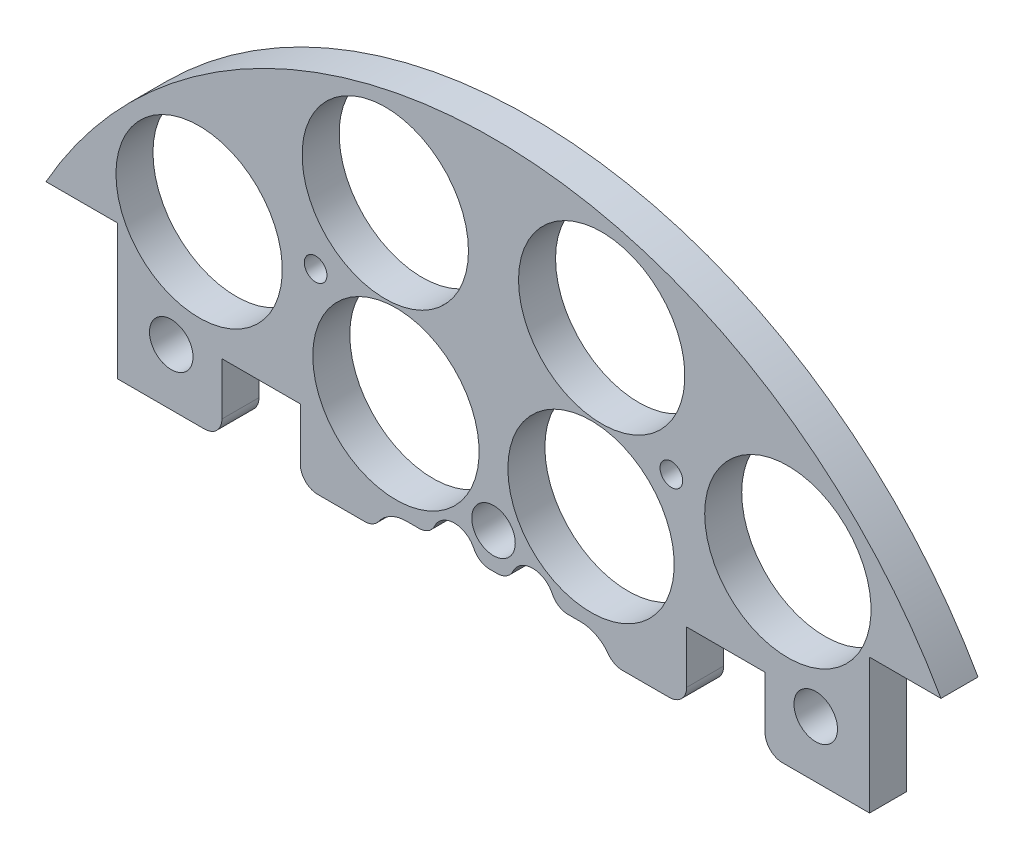
from build123d import *

# Parameters (mm, degrees)
SKETCH1_R                 = 1.651
BOSS_EXTRUDE2_DEPTH       = 5.3975
SKETCH2_R                 = 1.143
CUT_EXTRUDE1_DEPTH        = 6.3975
SKETCH3_R                 = 12.1285
CUT_EXTRUDE2_DEPTH        = 6.3975
SKETCH4_W                 = 28.562713242
SKETCH4_H                 = 11.677503754
BOSS_EXTRUDE3_DEPTH       = 5.3975
SKETCH5_W                 = 230.699333954
SKETCH5_H                 = 107.587024537
CUT_EXTRUDE3_DEPTH        = 6.3975
SKETCH6_R                 = 12.1285
CUT_EXTRUDE4_DEPTH        = 6.3975
SKETCH162_W               = 11.43
SKETCH162_H               = 10.16
CUT_EXTRUDE159_DEPTH      = 6.3975
SKETCH218_R               = 1.651
CUT_EXTRUDE215_DEPTH      = 97.79
SKETCH272_R               = 3.175
CUT_EXTRUDE269_DEPTH      = 103.378
CUT_EXTRUDE269_DEPTH_BACK = 48.768
CUT_EXTRUDE162_DEPTH      = 30.48
FILLET1_R                 = 2.54


with BuildPart() as part:
    # Sketch1 → Boss-Extrude2 (new body)
    with BuildSketch(Plane.XY):
        with BuildLine():
            Line((-65.2537815, 36.83), (-54.8397815, 36.83))
            Line((-54.8397815, 36.83), (-54.8397815, -36.83))
            Line((-54.8397815, -36.83), (-65.2537815, -36.83))
            ThreePointArc((-65.2537815, -36.83), (0, -74.93), (65.2537815, -36.83))
            Line((65.2537815, -36.83), (54.8397815, -36.83))
            Line((54.8397815, -36.83), (54.8397815, 36.83))
            Line((54.8397815, 36.83), (65.2537815, 36.83))
            ThreePointArc((65.2537815, 36.83), (0, 74.93), (-65.2537815, 36.83))
        make_face()
        with Locations((-45.466, 11.049)):
            Circle(SKETCH1_R, mode=Mode.SUBTRACT)
        with Locations((-20.067270032, 10.795)):
            Circle(SKETCH1_R, mode=Mode.SUBTRACT)
        with Locations((-20.067270032, -10.795)):
            Circle(SKETCH1_R, mode=Mode.SUBTRACT)
        with Locations((-45.466, -11.049)):
            Circle(SKETCH1_R, mode=Mode.SUBTRACT)
        with Locations((45.466, -11.049)):
            Circle(SKETCH1_R, mode=Mode.SUBTRACT)
        with Locations((20.067270032, -10.795)):
            Circle(SKETCH1_R, mode=Mode.SUBTRACT)
        with Locations((20.067270032, 10.795)):
            Circle(SKETCH1_R, mode=Mode.SUBTRACT)
        with Locations((45.466, 11.049)):
            Circle(SKETCH1_R, mode=Mode.SUBTRACT)
    extrude(amount=BOSS_EXTRUDE2_DEPTH)

    # Sketch2 → Cut-Extrude1 (cut, through all)
    with BuildSketch(Plane.XY.offset(5.3975)):
        with Locations((-6.731, 62.23)):
            Circle(SKETCH2_R)
        with Locations((6.731, 62.23)):
            Circle(SKETCH2_R)
    extrude(amount=-CUT_EXTRUDE1_DEPTH, mode=Mode.SUBTRACT)

    # Sketch3 → Cut-Extrude2 (cut, through all)
    with BuildSketch(Plane(origin=(0, 0, 0), x_dir=(-1, 0, 0), z_dir=(0, 0, -1))):
        with Locations((-14.224, -56.725087043)):
            Circle(SKETCH3_R)
        with Locations((14.224, -56.725087043)):
            Circle(SKETCH3_R)
        with Locations((-42.926, -42.926)):
            Circle(SKETCH3_R)
        with Locations((14.224, 34.29)):
            Circle(SKETCH3_R)
        with Locations((-14.224, 34.29)):
            Circle(SKETCH3_R)
        with Locations((-42.926, 42.926)):
            Circle(SKETCH3_R)
        with Locations((42.926, 42.926)):
            Circle(SKETCH3_R)
        with Locations((42.926, -42.926)):
            Circle(SKETCH3_R)
    extrude(amount=-CUT_EXTRUDE2_DEPTH, mode=Mode.SUBTRACT)

    # Sketch4 → Boss-Extrude3 (add)
    with BuildSketch(Plane(origin=(0, 0, 0), x_dir=(-1, 0, 0), z_dir=(0, 0, -1))):
        with Locations((-1.488809975, 62.152540216)):
            Rectangle(SKETCH4_W, SKETCH4_H)
    extrude(amount=-BOSS_EXTRUDE3_DEPTH)

    # Sketch5 → Cut-Extrude3 (cut, through all)
    with BuildSketch(Plane(origin=(0, 0, 0), x_dir=(-1, 0, 0), z_dir=(0, 0, -1))):
        with Locations((1.971047261, -36.648512269)):
            Rectangle(SKETCH5_W, SKETCH5_H)
    extrude(amount=-CUT_EXTRUDE3_DEPTH, mode=Mode.SUBTRACT)

    # Sketch6 → Cut-Extrude4 (cut, through all)
    with BuildSketch(Plane(origin=(0, 0, 0), x_dir=(-1, 0, 0), z_dir=(0, 0, -1))):
        with Locations((-15.777608989, 58.882838371)):
            Circle(SKETCH6_R)
        with Locations((15.777608989, 58.882838371)):
            Circle(SKETCH6_R)
    extrude(amount=-CUT_EXTRUDE4_DEPTH, mode=Mode.SUBTRACT)

    # Sketch162 → Cut-Extrude159 (cut, through all)
    with BuildSketch(Plane.XY.offset(5.3975)):
        with Locations((33.8847815, 22.225)):
            Rectangle(SKETCH162_W, SKETCH162_H)
        with Locations((-33.8847815, 22.225)):
            Rectangle(SKETCH162_W, SKETCH162_H)
    extrude(amount=-CUT_EXTRUDE159_DEPTH, mode=Mode.SUBTRACT)

    # Sketch218 → Cut-Extrude215 (cut)
    with BuildSketch(Plane(origin=(30.092005081, 4.08352975, -10.795), x_dir=(-1, 0, 0), z_dir=(0, 0, -1))):
        with Locations((4.154396091, 41.38247025)):
            Circle(SKETCH218_R)
        with Locations((56.02961407, 41.38247025)):
            Circle(SKETCH218_R)
    extrude(amount=-CUT_EXTRUDE215_DEPTH, mode=Mode.SUBTRACT)

    # Sketch272 → Cut-Extrude269 (cut, two sides)
    with BuildSketch(Plane(origin=(30.092005081, 4.08352975, 25.3365), x_dir=(-1, 0, 0), z_dir=(0, 0, -1))) as cut_extrude269_sk:
        with Locations((-16.897994919, 21.31647025)):
            Circle(SKETCH272_R)
        with Locations((77.082005081, 21.31647025)):
            Circle(SKETCH272_R)
        with Locations((30.092005081, 21.31647025)):
            Circle(SKETCH272_R)
    extrude(amount=CUT_EXTRUDE269_DEPTH, mode=Mode.SUBTRACT)
    extrude(cut_extrude269_sk.sketch, amount=-CUT_EXTRUDE269_DEPTH_BACK, mode=Mode.SUBTRACT)

    # Sketch165 → Cut-Extrude162 (cut)
    with BuildSketch(Plane(origin=(0, 0, 0), x_dir=(-1, 0, 0), z_dir=(0, 0, -1))):
        with BuildLine():
            Line((12.7, 20.24), (8.888991966, 20.24))
            ThreePointArc((8.888991966, 20.24), (5.715, 23.495), (2.541008034, 20.24))
            Line((2.541008034, 20.24), (-2.541008034, 20.24))
            ThreePointArc((-2.541008034, 20.24), (-5.715, 23.495), (-8.888991966, 20.24))
            Line((-8.888991966, 20.24), (-12.7, 20.24))
            ThreePointArc((-12.7, 20.24), (-16.235533906, 11.704466094), (-7.7, 15.24))
            Line((-7.7, 15.24), (7.7, 15.24))
            ThreePointArc((7.7, 15.24), (16.235533906, 11.704466094), (12.7, 20.24))
        make_face()
    extrude(amount=-CUT_EXTRUDE162_DEPTH, mode=Mode.SUBTRACT)

    # Fillet1
    fillet1_edges = [part.edges().sort_by_distance(p)[0] for p in [
        (39.5997815, 17.145, 2.69875),
        (28.1697815, 17.145, 2.69875),
        (-28.1697815, 17.145, 2.69875),
        (-39.5997815, 17.145, 2.69875),
        (-17.322875188, 17.145, 2.69875),
        (17.322875188, 17.145, 2.69875),
        (8.888991966, 20.24, 2.69875),
        (2.541008034, 20.24, 2.69875),
        (-2.541008034, 20.24, 2.69875),
        (-8.888991966, 20.24, 2.69875),
    ]]
    fillet(fillet1_edges, radius=FILLET1_R)


solid = part.part
